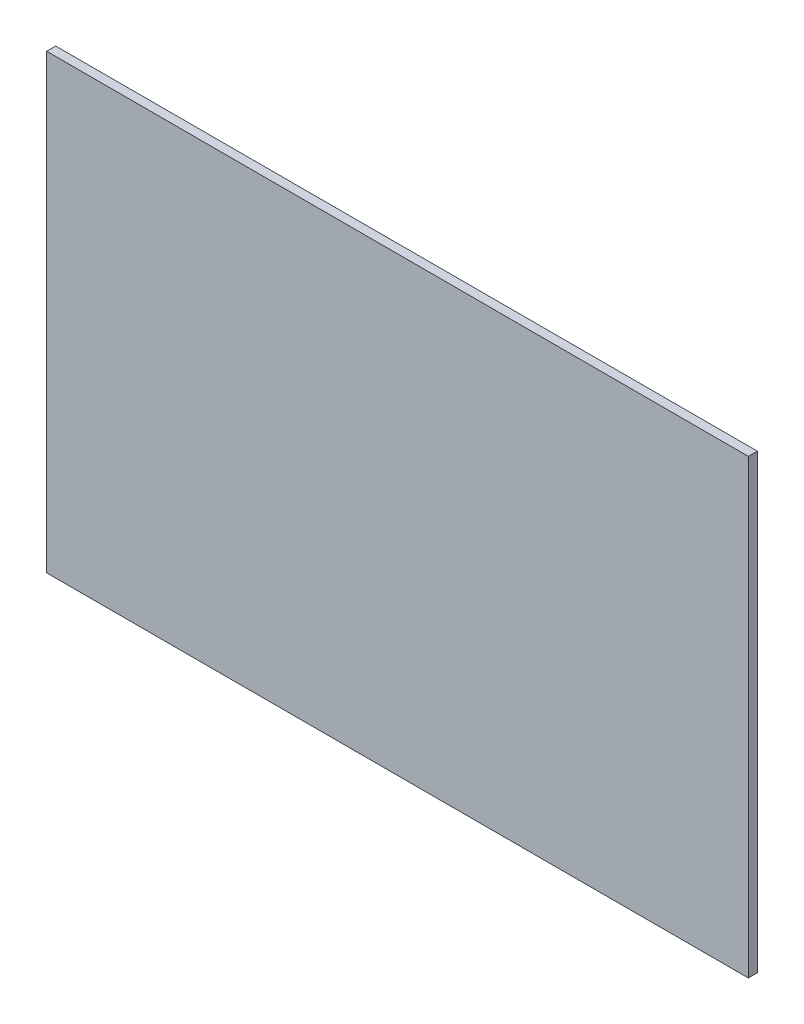
from build123d import *

# Parameters (mm, degrees)
SKETCH1_W           = 233
SKETCH1_H           = 150
BOSS_EXTRUDE1_DEPTH = 3


with BuildPart() as part:
    # Sketch1 → Boss-Extrude1 (new body)
    with BuildSketch(Plane.XY):
        with Locations((0, 29)):
            Rectangle(SKETCH1_W, SKETCH1_H)
    extrude(amount=BOSS_EXTRUDE1_DEPTH)


solid = part.part
